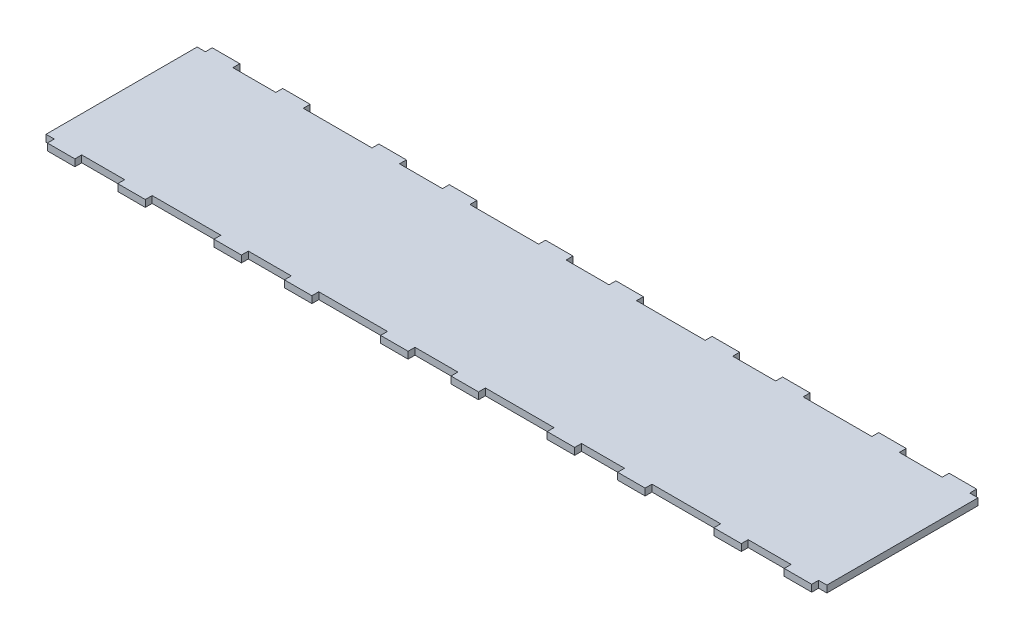
from build123d import *

# Parameters (mm, degrees)
SKETCH1_W                 = 721.63658441
SKETCH1_H                 = 152.4
BOSS_EXTRUDE1_DEPTH       = 6.35
SKETCH2_W                 = 39.679316882
SKETCH2_H                 = 6.35
SKETCH2_W_2               = 31.750000127
CUT_EXTRUDE1_DEPTH        = 7.35
LPATTERN1_COUNT           = 3
LPATTERN1_PITCH           = 153.979316882
LPATTERN1_COL_COUNT       = 3
LPATTERN1_COL_PITCH       = 153.979316882
MIRROR1_COPY_1_SKETCH_W   = 39.679316882
MIRROR1_COPY_1_SKETCH_H   = 6.35
MIRROR1_COPY_1_SKETCH_W_2 = 31.750000127
MIRROR1_COPY_1_DEPTH      = 7.35
MIRROR1_COPY_2_SKETCH_W   = 39.679316882
MIRROR1_COPY_2_SKETCH_H   = 6.35
MIRROR1_COPY_2_SKETCH_W_2 = 31.750000127
MIRROR1_COPY_2_DEPTH      = 7.35
MIRROR1_COPY_3_SKETCH_W   = 39.679316882
MIRROR1_COPY_3_SKETCH_H   = 6.35
MIRROR1_COPY_3_SKETCH_W_2 = 31.750000127
MIRROR1_COPY_3_DEPTH      = 7.35
MIRROR1_COPY_4_SKETCH_W   = 39.679316882
MIRROR1_COPY_4_SKETCH_H   = 6.35
MIRROR1_COPY_4_SKETCH_W_2 = 31.750000127
MIRROR1_COPY_4_DEPTH      = 7.35


with BuildPart() as part:
    # Sketch1 → Boss-Extrude1 (new body)
    with BuildSketch(Plane(origin=(0, 0, 0), x_dir=(1, 0, 0), z_dir=(0, 1, 0))):
        Rectangle(SKETCH1_W, SKETCH1_H)
    extrude(amount=BOSS_EXTRUDE1_DEPTH)

    # Sketch2 → Cut-Extrude1 (cut, through all)
    with BuildSketch(Plane(origin=(0, 6.35, 0), x_dir=(1, 0, 0), z_dir=(0, 1, 0))):
        with Locations((0, -73.025)):
            Rectangle(SKETCH2_W, SKETCH2_H)
        with Locations((-61.114658505, -73.025)):
            Rectangle(SKETCH2_W_2, SKETCH2_H)
        with Locations((61.114658505, -73.025)):
            Rectangle(SKETCH2_W_2, SKETCH2_H)
    cut_extrude1 = extrude(amount=-CUT_EXTRUDE1_DEPTH, mode=Mode.SUBTRACT)

    # LPattern1: Cut-Extrude1 ×3
    with Locations(*[(i * LPATTERN1_PITCH, 0, 0) for i in range(1, LPATTERN1_COUNT)]):
        add(cut_extrude1, mode=Mode.SUBTRACT)

    # LPattern1 col: Cut-Extrude1 ×3
    with Locations(*[(-i * LPATTERN1_COL_PITCH, 0, 0) for i in range(1, LPATTERN1_COL_COUNT)]):
        add(cut_extrude1, mode=Mode.SUBTRACT)

    # Mirror1: Cut-Extrude1 across plane
    add(cut_extrude1.mirror(Plane.XY), mode=Mode.SUBTRACT)

    # Mirror1 copy 1 sketch → Mirror1 copy 1 (cut, through all)
    with BuildSketch(Plane(origin=(153.979316882, 6.35, 0), x_dir=(1, 0, 0), z_dir=(0, 1, 0))):
        with Locations((0, 73.025)):
            Rectangle(MIRROR1_COPY_1_SKETCH_W, MIRROR1_COPY_1_SKETCH_H)
        with Locations((-61.114658505, 73.025)):
            Rectangle(MIRROR1_COPY_1_SKETCH_W_2, MIRROR1_COPY_1_SKETCH_H)
        with Locations((61.114658505, 73.025)):
            Rectangle(MIRROR1_COPY_1_SKETCH_W_2, MIRROR1_COPY_1_SKETCH_H)
    extrude(amount=-MIRROR1_COPY_1_DEPTH, mode=Mode.SUBTRACT)

    # Mirror1 copy 2 sketch → Mirror1 copy 2 (cut, through all)
    with BuildSketch(Plane(origin=(307.958633764, 6.35, 0), x_dir=(1, 0, 0), z_dir=(0, 1, 0))):
        with Locations((0, 73.025)):
            Rectangle(MIRROR1_COPY_2_SKETCH_W, MIRROR1_COPY_2_SKETCH_H)
        with Locations((-61.114658505, 73.025)):
            Rectangle(MIRROR1_COPY_2_SKETCH_W_2, MIRROR1_COPY_2_SKETCH_H)
        with Locations((61.114658505, 73.025)):
            Rectangle(MIRROR1_COPY_2_SKETCH_W_2, MIRROR1_COPY_2_SKETCH_H)
    extrude(amount=-MIRROR1_COPY_2_DEPTH, mode=Mode.SUBTRACT)

    # Mirror1 copy 3 sketch → Mirror1 copy 3 (cut, through all)
    with BuildSketch(Plane(origin=(-153.979316882, 6.35, 0), x_dir=(1, 0, 0), z_dir=(0, 1, 0))):
        with Locations((0, 73.025)):
            Rectangle(MIRROR1_COPY_3_SKETCH_W, MIRROR1_COPY_3_SKETCH_H)
        with Locations((-61.114658505, 73.025)):
            Rectangle(MIRROR1_COPY_3_SKETCH_W_2, MIRROR1_COPY_3_SKETCH_H)
        with Locations((61.114658505, 73.025)):
            Rectangle(MIRROR1_COPY_3_SKETCH_W_2, MIRROR1_COPY_3_SKETCH_H)
    extrude(amount=-MIRROR1_COPY_3_DEPTH, mode=Mode.SUBTRACT)

    # Mirror1 copy 4 sketch → Mirror1 copy 4 (cut, through all)
    with BuildSketch(Plane(origin=(-307.958633764, 6.35, 0), x_dir=(1, 0, 0), z_dir=(0, 1, 0))):
        with Locations((0, 73.025)):
            Rectangle(MIRROR1_COPY_4_SKETCH_W, MIRROR1_COPY_4_SKETCH_H)
        with Locations((-61.114658505, 73.025)):
            Rectangle(MIRROR1_COPY_4_SKETCH_W_2, MIRROR1_COPY_4_SKETCH_H)
        with Locations((61.114658505, 73.025)):
            Rectangle(MIRROR1_COPY_4_SKETCH_W_2, MIRROR1_COPY_4_SKETCH_H)
    extrude(amount=-MIRROR1_COPY_4_DEPTH, mode=Mode.SUBTRACT)


solid = part.part
